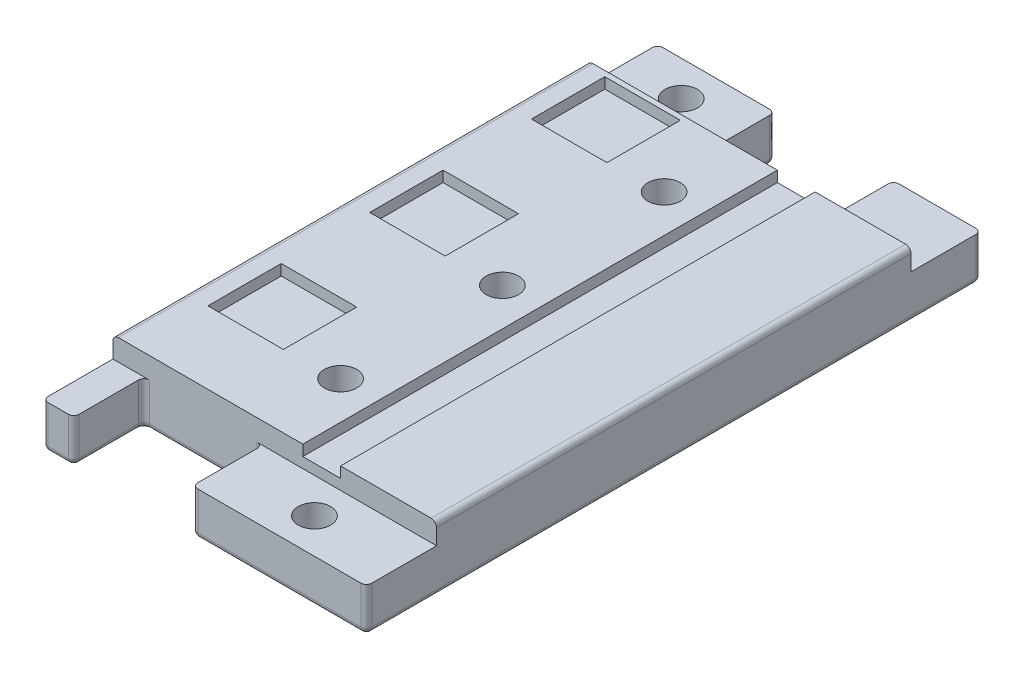
from build123d import *

# Parameters (mm, degrees)
SKETCH2_W           = 30
SKETCH2_H           = 44
BOSS_EXTRUDE1_DEPTH = 6
SKETCH4_W           = 10.879446424
SKETCH4_H           = 6.5
SKETCH4_W_2         = 8.120553576
SKETCH4_W_3         = 2.867356219
SKETCH4_W_4         = 16.132643781
BOSS_EXTRUDE2_DEPTH = 4.03177
SKETCH3_W           = 3.5
SKETCH3_H           = 44
SKETCH3_W_2         = 7
SKETCH3_H_2         = 6.8
CUT_EXTRUDE3_DEPTH  = 1
FILLET1_R           = 0.5
CUT_EXTRUDE4_REACH  = 8
SKETCH5_R           = 1.5
SKETCH6_R           = 1.5
CUT_EXTRUDE5_DEPTH  = 6


with BuildPart() as part:
    # Sketch2 → Boss-Extrude1 (new body)
    with BuildSketch(Plane(origin=(0, 1.96823021, 0), x_dir=(-1, 0, 0), z_dir=(0, -1, 0))):
        with Locations((-15, 0)):
            Rectangle(SKETCH2_W, SKETCH2_H)
    extrude(amount=BOSS_EXTRUDE1_DEPTH)

    # Sketch4 → Boss-Extrude2 (add)
    with BuildSketch(Plane(origin=(0, -4.03176979, 0), x_dir=(-1, 0, 0), z_dir=(0, -1, 0))):
        with Locations((-5.439723212, 25.25)):
            Rectangle(SKETCH4_W, SKETCH4_H)
        with Locations((-25.939723212, 25.25)):
            Rectangle(SKETCH4_W_2, SKETCH4_H)
        with Locations((-1.43367811, -25.25)):
            Rectangle(SKETCH4_W_3, SKETCH4_H)
        with Locations((-21.93367811, -25.25)):
            Rectangle(SKETCH4_W_4, SKETCH4_H)
    extrude(amount=-BOSS_EXTRUDE2_DEPTH)

    # Sketch3 → Cut-Extrude3 (cut)
    with BuildSketch(Plane(origin=(0, 1.96823021, 0), x_dir=(-1, 0, 0), z_dir=(0, -1, 0))):
        with Locations((-19.354808617, 0)):
            Rectangle(SKETCH3_W, SKETCH3_H)
        with Locations((-5.604808617, 3.1)):
            Rectangle(SKETCH3_W_2, SKETCH3_H_2)
        with Locations((-5.604808617, -11.9)):
            Rectangle(SKETCH3_W_2, SKETCH3_H_2)
        with Locations((-5.604808617, 18.1)):
            Rectangle(SKETCH3_W_2, SKETCH3_H_2)
    extrude(amount=CUT_EXTRUDE3_DEPTH, mode=Mode.SUBTRACT)

    # Fillet1
    fillet1_edges = [part.edges().sort_by_distance(p)[0] for p in [
        (0, -4.03176979, 0),
        (16.379446424, -4.03176979, -22),
        (5.439723212, -4.03176979, -28.5),
        (10.879446424, -4.03176979, -25.25),
        (10.879446424, -2.01588479, -28.5),
        (0, -2.01588479, -28.5),
        (21.879446424, -4.03176979, -25.25),
        (25.939723212, -4.03176979, -28.5),
        (21.879446424, -2.01588479, -28.5),
        (30, -2.01588479, -28.5),
        (2.867356219, -4.03176979, 25.25),
        (1.433678109, -4.03176979, 28.5),
        (2.867356219, -2.01588479, 22),
        (2.867356219, -2.01588479, 28.5),
        (0, -2.01588479, 28.5),
        (8.367356219, -4.03176979, 22),
        (21.933678109, -4.03176979, 28.5),
        (13.867356219, -4.03176979, 25.25),
        (13.867356219, -2.01588479, 28.5),
        (13.867356219, -2.01588479, 22),
        (30, -2.01588479, 28.5),
        (30, -4.03176979, 0),
        (0, 1.96823021, 0),
        (30, 1.96823021, 0),
    ]]
    fillet(fillet1_edges, radius=FILLET1_R)

    # Sketch5 → Cut-Extrude4 (cut, up to next)
    with BuildSketch(Plane(origin=(0, -4.03176979, 0), x_dir=(-1, 0, 0), z_dir=(0, -1, 0)), mode=Mode.PRIVATE) as cut_extrude4_sk1:
        with Locations((-5.439723212, 25.25)):
            Circle(SKETCH5_R)
    cut_extrude4_tool1 = extrude(cut_extrude4_sk1.sketch, amount=-CUT_EXTRUDE4_REACH, mode=Mode.PRIVATE) & part.part
    add(cut_extrude4_tool1.solids().sort_by_distance((5.439723, -4.03177, -25.25))[0], mode=Mode.SUBTRACT)
    # Sketch5 → Cut-Extrude4 (cut, up to next)
    with BuildSketch(Plane(origin=(0, -4.03176979, 0), x_dir=(-1, 0, 0), z_dir=(0, -1, 0)), mode=Mode.PRIVATE) as cut_extrude4_sk2:
        with Locations((-21.933678109, -25.25)):
            Circle(SKETCH5_R)
    cut_extrude4_tool2 = extrude(cut_extrude4_sk2.sketch, amount=-CUT_EXTRUDE4_REACH, mode=Mode.PRIVATE) & part.part
    add(cut_extrude4_tool2.solids().sort_by_distance((21.933678, -4.03177, 25.25))[0], mode=Mode.SUBTRACT)

    # Sketch6 → Cut-Extrude5 (cut)
    with BuildSketch(Plane.XZ.offset(4.03176979)):
        with Locations((14.104808617, -15)):
            Circle(SKETCH6_R)
        with Locations((14.104808617, 0)):
            Circle(SKETCH6_R)
        with Locations((14.104808617, 15)):
            Circle(SKETCH6_R)
    extrude(amount=-CUT_EXTRUDE5_DEPTH, mode=Mode.SUBTRACT)


solid = part.part
